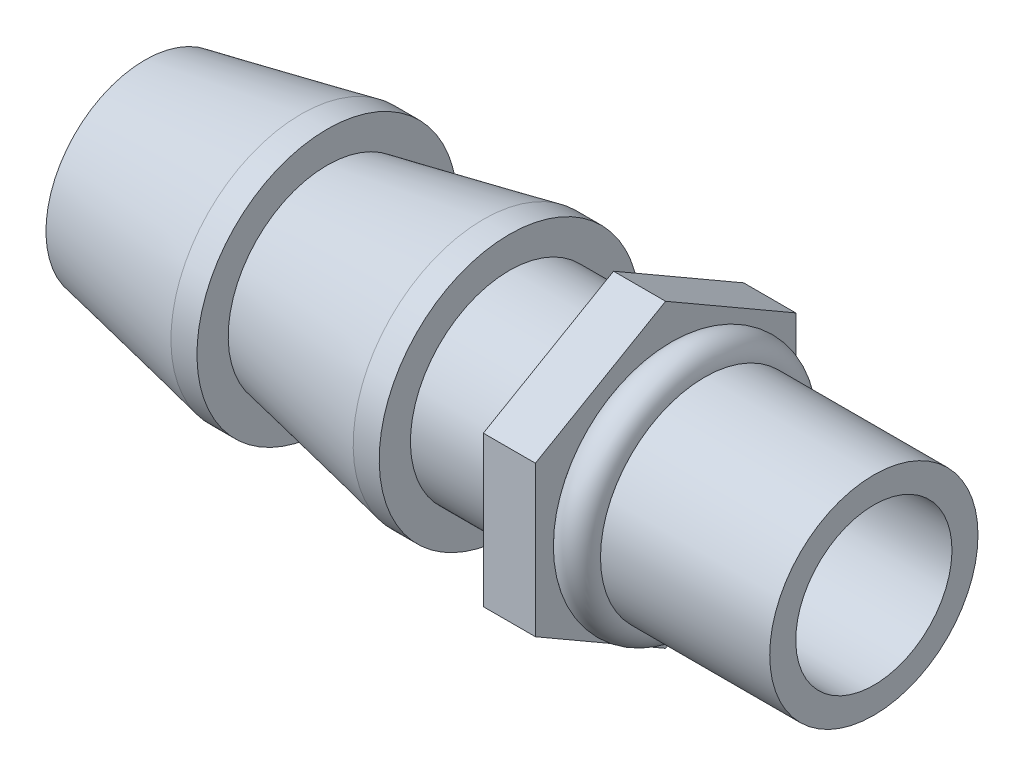
from build123d import *

# Parameters (mm, degrees)
ESQUISSE1_R        = 0.375
ESQUISSE2_R        = 1.5
BOSS_EXTRU_1_DEPTH = 1
ESQUISSE3_R        = 2
ESQUISSE3_R_2      = 1.5
BOSS_EXTRU_2_DEPTH = 4


with BuildPart() as part:
    # Esquisse1 → Révolution1 (revolve)
    with BuildSketch(Plane.XY):
        with Locations((-0.375, 2)):
            Circle(ESQUISSE1_R)
        Polygon((-10.75, 1.5), (-1.75, 1.5), (-1.75, 1.9), (-3.75, 1.9), (-3.75, 2.5), (-4.25, 2.5), (-7.25, 1.9), (-7.25, 2.5), (-7.75, 2.5), (-10.75, 1.9), align=None)
    revolve(axis=Axis((0, 0, 0), (-1, 0, 0)))

    # Esquisse2 → Boss.-Extru.1 (add)
    with BuildSketch(Plane(origin=(-1.75, 0, 0), x_dir=(0, 0, -1), z_dir=(1, 0, 0))):
        Polygon((-2.5, -1.443375673), (-2.5, 1.443375673), (0, 2.886751346), (2.5, 1.443375673), (2.5, -1.443375673), (0, -2.886751346), align=None)
        with Locations(Location((0, 0, 0), (0, 0, 90))):
            Circle(ESQUISSE2_R, mode=Mode.SUBTRACT)
    extrude(amount=BOSS_EXTRU_1_DEPTH)

    # Esquisse3 → Boss.-Extru.2 (add)
    with BuildSketch(Plane(origin=(-0.75, 0, 0), x_dir=(0, 0, -1), z_dir=(1, 0, 0))):
        with Locations(Location((0, 0, 0), (0, 0, 270))):
            Circle(ESQUISSE3_R)
        with Locations(Location((0, 0, 0), (0, 0, 90))):
            Circle(ESQUISSE3_R_2, mode=Mode.SUBTRACT)
    extrude(amount=BOSS_EXTRU_2_DEPTH)


solid = part.part
